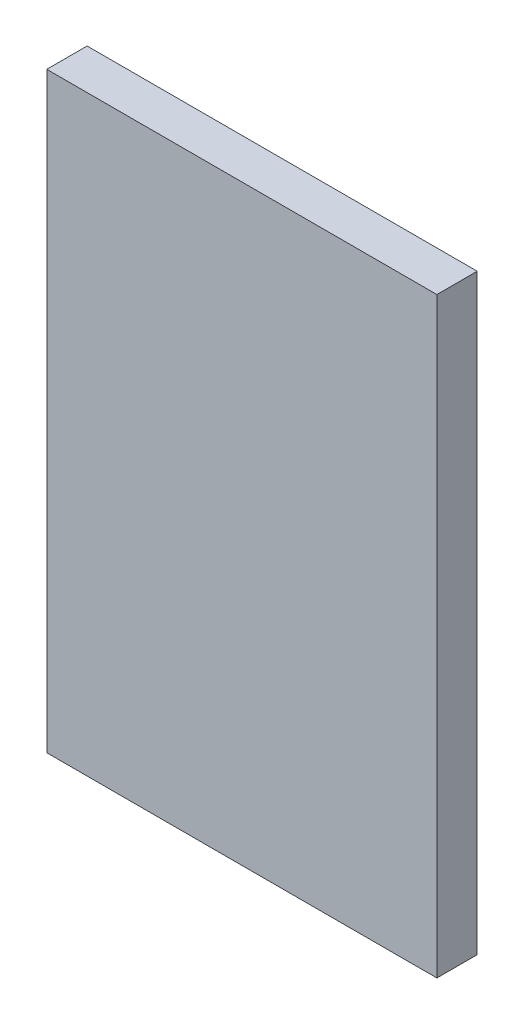
from build123d import *

# Parameters (mm, degrees)
SKETCH1_W           = 184.15
SKETCH1_H           = 279.4
BOSS_EXTRUDE1_DEPTH = 19.05


with BuildPart() as part:
    # Sketch1 → Boss-Extrude1 (new body)
    with BuildSketch(Plane.XY):
        Rectangle(SKETCH1_W, SKETCH1_H)
    extrude(amount=BOSS_EXTRUDE1_DEPTH)


solid = part.part
